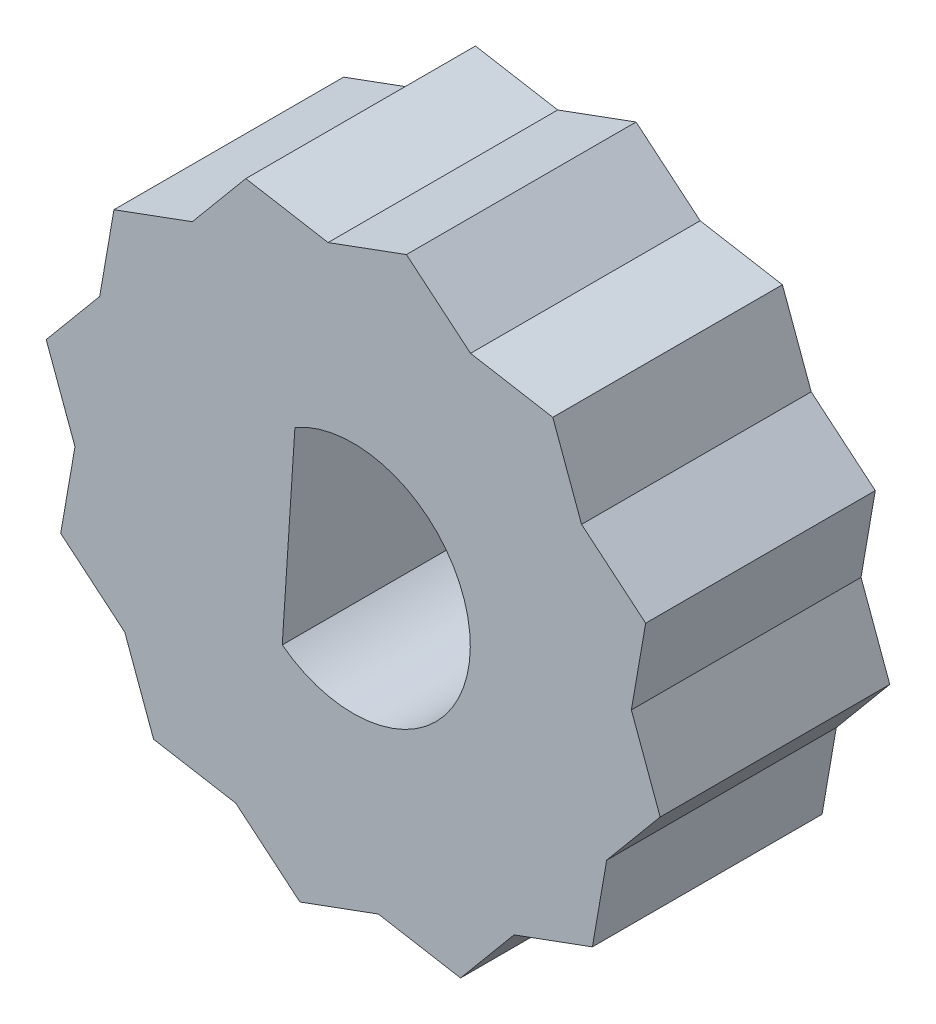
from build123d import *

# Parameters (mm, degrees)
BOSS_EXTRUDE2_DEPTH = 10


with BuildPart() as part:
    # Sketch1 → Boss-Extrude2 (new body)
    with BuildSketch(Plane.XY):
        Polygon((9.945212763, 7.004832947), (8.692356553, 10.417594294), (5.110390425, 11.038969663), (2.319004447, 13.368079582), (-1.0937569, 12.115223372), (-4.675723029, 12.736598741), (-7.004832947, 9.945212763), (-10.417594294, 8.692356553), (-11.038969663, 5.110390425), (-13.368079582, 2.319004447), (-12.115223372, -1.0937569), (-12.736598741, -4.675723029), (-9.945212763, -7.004832947), (-8.692356553, -10.417594294), (-5.110390425, -11.038969663), (-2.319004447, -13.368079582), (1.0937569, -12.115223372), (4.675723029, -12.736598741), (7.004832947, -9.945212763), (10.417594294, -8.692356553), (11.038969663, -5.110390425), (13.368079582, -2.319004447), (12.115223372, 1.0937569), (12.736598741, 4.675723029), align=None)
        with BuildLine():
            Line((-3.08920951, -4.05792861), (-2.537148142, 4.424124694))
            ThreePointArc((-2.537148142, 4.424124694), (5.089231982, -0.331236821), (-3.08920951, -4.05792861))
        make_face(mode=Mode.SUBTRACT)
    extrude(amount=BOSS_EXTRUDE2_DEPTH)


solid = part.part
